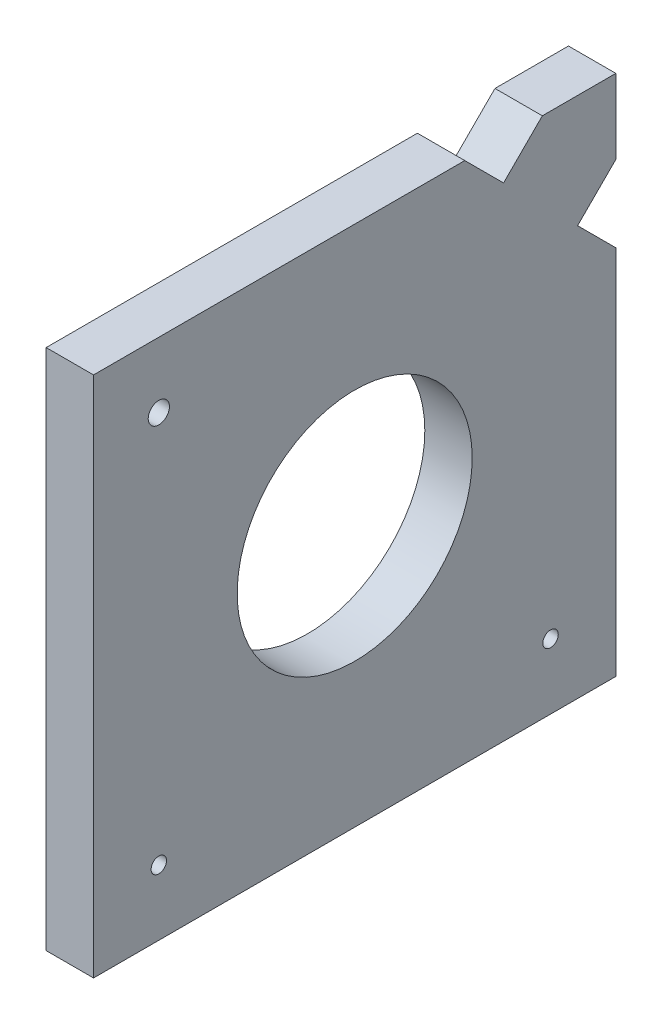
from build123d import *

# Parameters (mm, degrees)
SKETCH1_R           = 15.748
BOSS_EXTRUDE1_DEPTH = 6.35
SKETCH2_R           = 1.4224
SKETCH2_R_2         = 1.03251
CUT_EXTRUDE1_DEPTH  = 6.35


with BuildPart() as part:
    # Sketch1 → Boss-Extrude1 (new body)
    with BuildSketch(Plane(origin=(0, 0, 0), x_dir=(0, 0, -1), z_dir=(1, 0, 0))):
        Polygon((0, 0), (70, 0), (70, 49.756615014), (64.872483647, 54.884131367), (70, 60.011647719), (70, 70), (60.148635267, 70), (54.952625141, 64.803989874), (49.756615014, 70), (0, 70), align=None)
        with Locations((35, 35)):
            Circle(SKETCH1_R, mode=Mode.SUBTRACT)
    extrude(amount=BOSS_EXTRUDE1_DEPTH)

    # Sketch2 → Cut-Extrude1 (cut)
    with BuildSketch(Plane(origin=(6.35, 0, 0), x_dir=(0, 0, -1), z_dir=(1, 0, 0))):
        with Locations((8.75, 61.25)):
            Circle(SKETCH2_R)
        with Locations((8.75, 8.75)):
            Circle(SKETCH2_R_2)
        with Locations((61.25, 8.75)):
            Circle(SKETCH2_R_2)
    extrude(amount=-CUT_EXTRUDE1_DEPTH, mode=Mode.SUBTRACT)


solid = part.part
